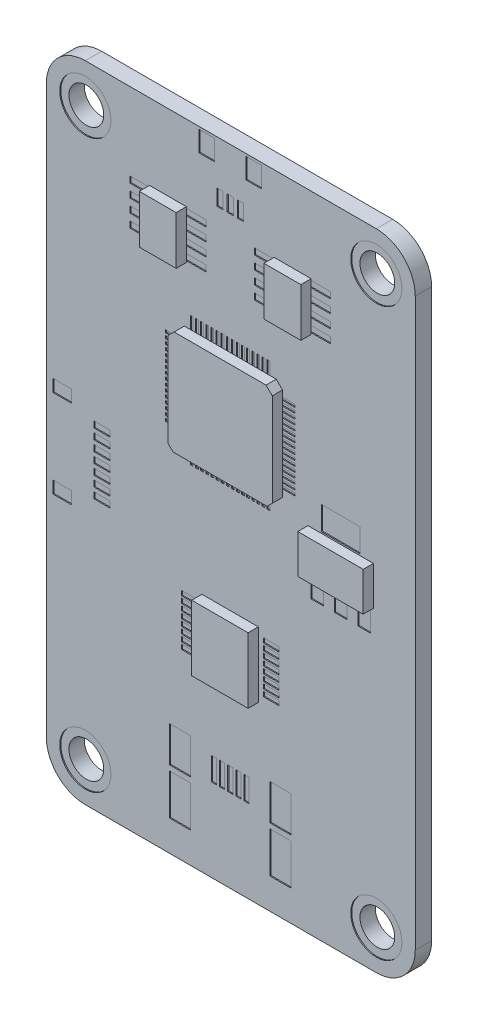
from build123d import *

# Parameters (mm, degrees)
SKETCH2_R           = 1.6999966
BOSS_EXTRUDE1_DEPTH = 1.6
SKETCH3_R           = 2.499995
SKETCH3_W           = 2.2098
SKETCH3_H           = 0.6096
SKETCH3_W_2         = 0.26924
SKETCH3_H_2         = 1.45034
SKETCH3_W_3         = 0.499999
SKETCH3_H_3         = 2.2499828
SKETCH3_W_4         = 2.0500086
SKETCH3_H_4         = 3.5000184
SKETCH3_H_5         = 3.999992
SKETCH3_W_5         = 1.5500096
SKETCH3_H_6         = 0.5999988
SKETCH3_W_6         = 1.7999964
SKETCH3_H_7         = 1.1999976
SKETCH3_W_7         = 1.499997
SKETCH3_H_8         = 1.999996
SKETCH3_W_8         = 0.5999988
SKETCH3_H_9         = 1.5500096
SKETCH3_W_9         = 1.45034
SKETCH3_H_10        = 0.26924
SKETCH3_W_10        = 1.524
SKETCH3_H_11        = 0.450088
SKETCH3_W_11        = 3.7999924
SKETCH3_H_12        = 2.2999954
SKETCH3_W_12        = 1.1999976
CUT_EXTRUDE1_DEPTH  = 0.1
SKETCH4_W           = 5.509768
SKETCH4_H           = 6.400292
SKETCH4_W_2         = 3.6068
SKETCH4_H_2         = 4.7244
SKETCH4_W_3         = 6.3999872
SKETCH4_H_3         = 3.7999924
BOSS_EXTRUDE2_DEPTH = 1


with BuildPart() as part:
    # Sketch2 → Boss-Extrude1 (new body)
    with BuildSketch(Plane.XY):
        with BuildLine():
            Line((36.068, 59.182), (36.068, 3.81))
            ThreePointArc((36.068, 3.81), (34.952076836, 1.115923164), (32.258, 0))
            Line((32.258, 0), (3.81, 0))
            ThreePointArc((3.81, 0), (1.115923164, 1.115923164), (0, 3.81))
            Line((0, 3.81), (0, 59.182))
            ThreePointArc((0, 59.182), (1.115923164, 61.876076836), (3.81, 62.992))
            Line((3.81, 62.992), (32.258, 62.992))
            ThreePointArc((32.258, 62.992), (34.952076836, 61.876076836), (36.068, 59.182))
        make_face()
        with Locations((3.81, 59.182)):
            Circle(SKETCH2_R, mode=Mode.SUBTRACT)
        with Locations((32.258, 59.182)):
            Circle(SKETCH2_R, mode=Mode.SUBTRACT)
        with Locations((3.81, 3.81)):
            Circle(SKETCH2_R, mode=Mode.SUBTRACT)
        with Locations((32.258, 3.81)):
            Circle(SKETCH2_R, mode=Mode.SUBTRACT)
    extrude(amount=-BOSS_EXTRUDE1_DEPTH)

    # Sketch3 → Cut-Extrude1 (cut)
    with BuildSketch(Plane.XY):
        with Locations((32.258, 59.182)):
            Circle(SKETCH3_R)
        with Locations((3.81, 3.81)):
            Circle(SKETCH3_R)
        with Locations((3.81, 59.182)):
            Circle(SKETCH3_R)
        with Locations((32.258, 3.81)):
            Circle(SKETCH3_R)
        with Locations((21.463, 55.118)):
            Rectangle(SKETCH3_W, SKETCH3_H)
        with Locations((14.724, 34.6456)):
            Rectangle(SKETCH3_W_2, SKETCH3_H_2)
        with Locations((16.3831397, 9.2120212)):
            Rectangle(SKETCH3_W_3, SKETCH3_H_3)
        with Locations((17.1832397, 9.2120212)):
            Rectangle(SKETCH3_W_3, SKETCH3_H_3)
        with Locations((17.9833397, 9.2120212)):
            Rectangle(SKETCH3_W_3, SKETCH3_H_3)
        with Locations((18.7831857, 9.2120212)):
            Rectangle(SKETCH3_W_3, SKETCH3_H_3)
        with Locations((19.5832857, 9.2120212)):
            Rectangle(SKETCH3_W_3, SKETCH3_H_3)
        with Locations((22.9081965, 9.2369894)):
            Rectangle(SKETCH3_W_4, SKETCH3_H_4)
        with Locations((22.9081965, 4.9870106)):
            Rectangle(SKETCH3_W_4, SKETCH3_H_5)
        with Locations((13.0582035, 9.2369894)):
            Rectangle(SKETCH3_W_4, SKETCH3_H_4)
        with Locations((13.0582035, 4.9870106)):
            Rectangle(SKETCH3_W_4, SKETCH3_H_5)
        with Locations((5.4417214, 32.6189594)):
            Rectangle(SKETCH3_W_5, SKETCH3_H_6)
        with Locations((5.4417214, 31.6189614)):
            Rectangle(SKETCH3_W_5, SKETCH3_H_6)
        with Locations((5.4417214, 30.6189634)):
            Rectangle(SKETCH3_W_5, SKETCH3_H_6)
        with Locations((5.4417214, 29.61894)):
            Rectangle(SKETCH3_W_5, SKETCH3_H_6)
        with Locations((5.4417214, 28.6189166)):
            Rectangle(SKETCH3_W_5, SKETCH3_H_6)
        with Locations((5.4417214, 27.6189948)):
            Rectangle(SKETCH3_W_5, SKETCH3_H_6)
        with Locations((5.4417214, 26.6189714)):
            Rectangle(SKETCH3_W_5, SKETCH3_H_6)
        with Locations((1.5667228, 25.318974)):
            Rectangle(SKETCH3_W_6, SKETCH3_H_7)
        with Locations((1.5667228, 33.9189568)):
            Rectangle(SKETCH3_W_6, SKETCH3_H_7)
        with Locations((15.6831919, 61.7544866)):
            Rectangle(SKETCH3_W_7, SKETCH3_H_8)
        with Locations((20.2831827, 61.7544866)):
            Rectangle(SKETCH3_W_7, SKETCH3_H_8)
        with Locations((16.983202, 57.879488)):
            Rectangle(SKETCH3_W_8, SKETCH3_H_9)
        with Locations((17.9832, 57.879488)):
            Rectangle(SKETCH3_W_8, SKETCH3_H_9)
        with Locations((18.983198, 57.879488)):
            Rectangle(SKETCH3_W_8, SKETCH3_H_9)
        with Locations((14.224, 34.6456)):
            Rectangle(SKETCH3_W_2, SKETCH3_H_2)
        with Locations((15.224, 34.6456)):
            Rectangle(SKETCH3_W_2, SKETCH3_H_2)
        with Locations((15.724, 34.6456)):
            Rectangle(SKETCH3_W_2, SKETCH3_H_2)
        with Locations((16.224, 34.6456)):
            Rectangle(SKETCH3_W_2, SKETCH3_H_2)
        with Locations((16.724, 34.6456)):
            Rectangle(SKETCH3_W_2, SKETCH3_H_2)
        with Locations((17.224, 34.6456)):
            Rectangle(SKETCH3_W_2, SKETCH3_H_2)
        with Locations((17.724, 34.6456)):
            Rectangle(SKETCH3_W_2, SKETCH3_H_2)
        with Locations((18.224, 34.6456)):
            Rectangle(SKETCH3_W_2, SKETCH3_H_2)
        with Locations((18.724, 34.6456)):
            Rectangle(SKETCH3_W_2, SKETCH3_H_2)
        with Locations((19.224, 34.6456)):
            Rectangle(SKETCH3_W_2, SKETCH3_H_2)
        with Locations((19.724, 34.6456)):
            Rectangle(SKETCH3_W_2, SKETCH3_H_2)
        with Locations((20.224, 34.6456)):
            Rectangle(SKETCH3_W_2, SKETCH3_H_2)
        with Locations((20.724, 34.6456)):
            Rectangle(SKETCH3_W_2, SKETCH3_H_2)
        with Locations((21.224, 34.6456)):
            Rectangle(SKETCH3_W_2, SKETCH3_H_2)
        with Locations((21.724, 34.6456)):
            Rectangle(SKETCH3_W_2, SKETCH3_H_2)
        with Locations((14.724, 45.8456)):
            Rectangle(SKETCH3_W_2, SKETCH3_H_2)
        with Locations((15.224, 45.8456)):
            Rectangle(SKETCH3_W_2, SKETCH3_H_2)
        with Locations((15.724, 45.8456)):
            Rectangle(SKETCH3_W_2, SKETCH3_H_2)
        with Locations((16.224, 45.8456)):
            Rectangle(SKETCH3_W_2, SKETCH3_H_2)
        with Locations((16.724, 45.8456)):
            Rectangle(SKETCH3_W_2, SKETCH3_H_2)
        with Locations((17.224, 45.8456)):
            Rectangle(SKETCH3_W_2, SKETCH3_H_2)
        with Locations((17.724, 45.8456)):
            Rectangle(SKETCH3_W_2, SKETCH3_H_2)
        with Locations((18.224, 45.8456)):
            Rectangle(SKETCH3_W_2, SKETCH3_H_2)
        with Locations((18.724, 45.8456)):
            Rectangle(SKETCH3_W_2, SKETCH3_H_2)
        with Locations((19.224, 45.8456)):
            Rectangle(SKETCH3_W_2, SKETCH3_H_2)
        with Locations((19.724, 45.8456)):
            Rectangle(SKETCH3_W_2, SKETCH3_H_2)
        with Locations((20.224, 45.8456)):
            Rectangle(SKETCH3_W_2, SKETCH3_H_2)
        with Locations((20.724, 45.8456)):
            Rectangle(SKETCH3_W_2, SKETCH3_H_2)
        with Locations((21.224, 45.8456)):
            Rectangle(SKETCH3_W_2, SKETCH3_H_2)
        with Locations((21.724, 45.8456)):
            Rectangle(SKETCH3_W_2, SKETCH3_H_2)
        with Locations((14.224, 45.8456)):
            Rectangle(SKETCH3_W_2, SKETCH3_H_2)
        with Locations((23.5698, 44.0182)):
            Rectangle(SKETCH3_W_9, SKETCH3_H_10)
        with Locations((12.3698, 44.0182)):
            Rectangle(SKETCH3_W_9, SKETCH3_H_10)
        with Locations((23.5698, 43.5182)):
            Rectangle(SKETCH3_W_9, SKETCH3_H_10)
        with Locations((23.5698, 43.0182)):
            Rectangle(SKETCH3_W_9, SKETCH3_H_10)
        with Locations((23.5698, 42.5182)):
            Rectangle(SKETCH3_W_9, SKETCH3_H_10)
        with Locations((23.5698, 42.0182)):
            Rectangle(SKETCH3_W_9, SKETCH3_H_10)
        with Locations((23.5698, 41.5182)):
            Rectangle(SKETCH3_W_9, SKETCH3_H_10)
        with Locations((23.5698, 41.0182)):
            Rectangle(SKETCH3_W_9, SKETCH3_H_10)
        with Locations((23.5698, 40.5182)):
            Rectangle(SKETCH3_W_9, SKETCH3_H_10)
        with Locations((23.5698, 40.0182)):
            Rectangle(SKETCH3_W_9, SKETCH3_H_10)
        with Locations((23.5698, 39.5182)):
            Rectangle(SKETCH3_W_9, SKETCH3_H_10)
        with Locations((23.5698, 39.0182)):
            Rectangle(SKETCH3_W_9, SKETCH3_H_10)
        with Locations((23.5698, 38.5182)):
            Rectangle(SKETCH3_W_9, SKETCH3_H_10)
        with Locations((23.5698, 38.0182)):
            Rectangle(SKETCH3_W_9, SKETCH3_H_10)
        with Locations((23.5698, 37.5182)):
            Rectangle(SKETCH3_W_9, SKETCH3_H_10)
        with Locations((23.5698, 37.0182)):
            Rectangle(SKETCH3_W_9, SKETCH3_H_10)
        with Locations((23.5698, 36.5182)):
            Rectangle(SKETCH3_W_9, SKETCH3_H_10)
        with Locations((12.3698, 43.5182)):
            Rectangle(SKETCH3_W_9, SKETCH3_H_10)
        with Locations((12.3698, 43.0182)):
            Rectangle(SKETCH3_W_9, SKETCH3_H_10)
        with Locations((12.3698, 42.5182)):
            Rectangle(SKETCH3_W_9, SKETCH3_H_10)
        with Locations((12.3698, 42.0182)):
            Rectangle(SKETCH3_W_9, SKETCH3_H_10)
        with Locations((12.3698, 41.5182)):
            Rectangle(SKETCH3_W_9, SKETCH3_H_10)
        with Locations((12.3698, 41.0182)):
            Rectangle(SKETCH3_W_9, SKETCH3_H_10)
        with Locations((12.3698, 40.5182)):
            Rectangle(SKETCH3_W_9, SKETCH3_H_10)
        with Locations((12.3698, 40.0182)):
            Rectangle(SKETCH3_W_9, SKETCH3_H_10)
        with Locations((12.3698, 39.5182)):
            Rectangle(SKETCH3_W_9, SKETCH3_H_10)
        with Locations((12.3698, 39.0182)):
            Rectangle(SKETCH3_W_9, SKETCH3_H_10)
        with Locations((12.3698, 38.5182)):
            Rectangle(SKETCH3_W_9, SKETCH3_H_10)
        with Locations((12.3698, 38.0182)):
            Rectangle(SKETCH3_W_9, SKETCH3_H_10)
        with Locations((12.3698, 37.5182)):
            Rectangle(SKETCH3_W_9, SKETCH3_H_10)
        with Locations((12.3698, 37.0182)):
            Rectangle(SKETCH3_W_9, SKETCH3_H_10)
        with Locations((12.3698, 36.5182)):
            Rectangle(SKETCH3_W_9, SKETCH3_H_10)
        with Locations((21.9812014, 22.6229418)):
            Rectangle(SKETCH3_W_10, SKETCH3_H_11)
        with Locations((13.9812014, 22.6229418)):
            Rectangle(SKETCH3_W_10, SKETCH3_H_11)
        with Locations((21.9812014, 21.9729418)):
            Rectangle(SKETCH3_W_10, SKETCH3_H_11)
        with Locations((21.9812014, 21.3229418)):
            Rectangle(SKETCH3_W_10, SKETCH3_H_11)
        with Locations((21.9812014, 20.6729418)):
            Rectangle(SKETCH3_W_10, SKETCH3_H_11)
        with Locations((21.9812014, 20.0229418)):
            Rectangle(SKETCH3_W_10, SKETCH3_H_11)
        with Locations((21.9812014, 19.3729418)):
            Rectangle(SKETCH3_W_10, SKETCH3_H_11)
        with Locations((21.9812014, 18.7229418)):
            Rectangle(SKETCH3_W_10, SKETCH3_H_11)
        with Locations((21.9812014, 18.0729418)):
            Rectangle(SKETCH3_W_10, SKETCH3_H_11)
        with Locations((13.9812014, 21.9729418)):
            Rectangle(SKETCH3_W_10, SKETCH3_H_11)
        with Locations((13.9812014, 21.3229418)):
            Rectangle(SKETCH3_W_10, SKETCH3_H_11)
        with Locations((13.9812014, 20.6729418)):
            Rectangle(SKETCH3_W_10, SKETCH3_H_11)
        with Locations((13.9812014, 20.0229418)):
            Rectangle(SKETCH3_W_10, SKETCH3_H_11)
        with Locations((13.9812014, 19.3729418)):
            Rectangle(SKETCH3_W_10, SKETCH3_H_11)
        with Locations((13.9812014, 18.7229418)):
            Rectangle(SKETCH3_W_10, SKETCH3_H_11)
        with Locations((13.9812014, 18.0729418)):
            Rectangle(SKETCH3_W_10, SKETCH3_H_11)
        with Locations((9.271, 55.118)):
            Rectangle(SKETCH3_W, SKETCH3_H)
        with Locations((9.271, 53.848)):
            Rectangle(SKETCH3_W, SKETCH3_H)
        with Locations((9.271, 52.578)):
            Rectangle(SKETCH3_W, SKETCH3_H)
        with Locations((9.271, 51.308)):
            Rectangle(SKETCH3_W, SKETCH3_H)
        with Locations((14.5034, 55.118)):
            Rectangle(SKETCH3_W, SKETCH3_H)
        with Locations((14.5034, 53.848)):
            Rectangle(SKETCH3_W, SKETCH3_H)
        with Locations((14.5034, 52.578)):
            Rectangle(SKETCH3_W, SKETCH3_H)
        with Locations((14.5034, 51.308)):
            Rectangle(SKETCH3_W, SKETCH3_H)
        with Locations((21.463, 53.848)):
            Rectangle(SKETCH3_W, SKETCH3_H)
        with Locations((21.463, 52.578)):
            Rectangle(SKETCH3_W, SKETCH3_H)
        with Locations((21.463, 51.308)):
            Rectangle(SKETCH3_W, SKETCH3_H)
        with Locations((26.6954, 55.118)):
            Rectangle(SKETCH3_W, SKETCH3_H)
        with Locations((26.6954, 53.848)):
            Rectangle(SKETCH3_W, SKETCH3_H)
        with Locations((26.6954, 52.578)):
            Rectangle(SKETCH3_W, SKETCH3_H)
        with Locations((26.6954, 51.308)):
            Rectangle(SKETCH3_W, SKETCH3_H)
        with Locations((28.7782, 35.8139873)):
            Rectangle(SKETCH3_W_11, SKETCH3_H_12)
        with Locations((26.47823, 29.464)):
            Rectangle(SKETCH3_W_12, SKETCH3_H_8)
        with Locations((28.7782, 29.464)):
            Rectangle(SKETCH3_W_12, SKETCH3_H_8)
        with Locations((31.07817, 29.464)):
            Rectangle(SKETCH3_W_12, SKETCH3_H_8)
    extrude(amount=-CUT_EXTRUDE1_DEPTH, mode=Mode.SUBTRACT)

    # Sketch4 → Boss-Extrude2 (add)
    with BuildSketch(Plane.XY):
        Polygon((13.3858, 35.1536), (22.5806, 35.1536), (23.0886, 35.6616), (23.0886, 44.7548), (22.479, 45.3644), (13.4874, 45.3644), (12.8778, 44.7548), (12.8778, 35.6616), align=None)
        with Locations((17.9677314, 20.3168758)):
            Rectangle(SKETCH4_W, SKETCH4_H)
        with Locations((11.8872, 53.213)):
            Rectangle(SKETCH4_W_2, SKETCH4_H_2)
        with Locations((24.0792, 53.213)):
            Rectangle(SKETCH4_W_2, SKETCH4_H_2)
        with Locations((28.7782, 32.613981)):
            Rectangle(SKETCH4_W_3, SKETCH4_H_3)
    extrude(amount=BOSS_EXTRUDE2_DEPTH)


solid = part.part
